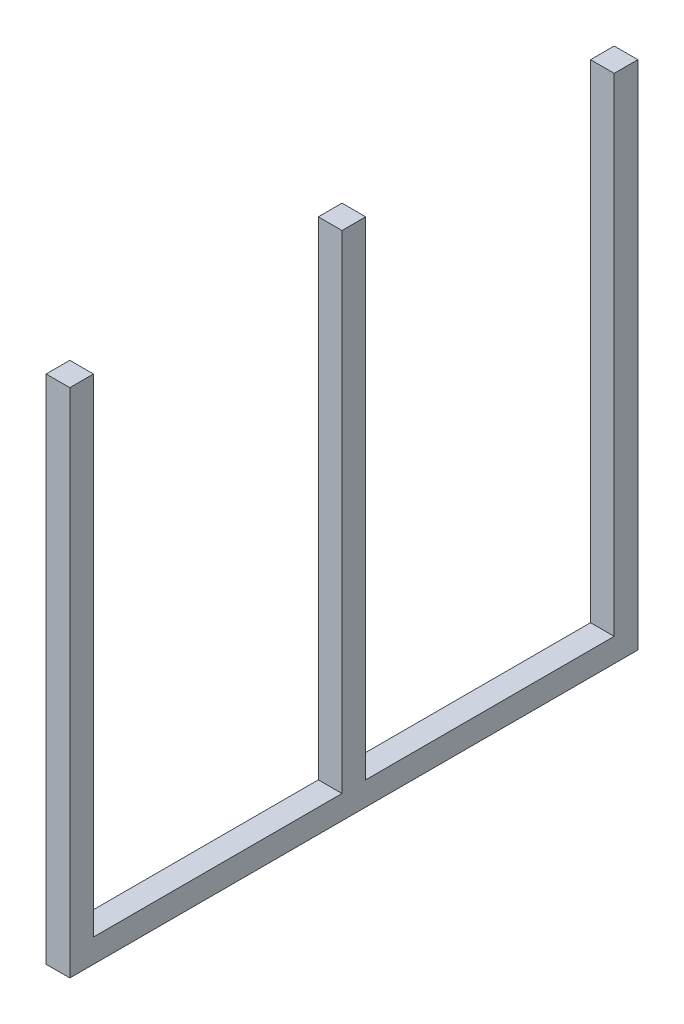
from build123d import *

# Parameters (mm, degrees)
SKETCH1_W           = 31.75
SKETCH1_H           = 31.75
SKETCH1_W_2         = 24.13
SKETCH1_H_2         = 24.13
BOSS_EXTRUDE1_DEPTH = 762
SKETCH14_W          = 31.75
SKETCH14_H          = 31.75
SKETCH14_W_2        = 25.4
SKETCH14_H_2        = 25.4
BOSS_EXTRUDE2_DEPTH = 685.8
SKETCH14_2_W        = 25.4
SKETCH14_2_H        = 25.4
BOSS_EXTRUDE3_DEPTH = 2.54
BOSS_EXTRUDE6_START = -683.26
SKETCH14_3_W        = 25.4
SKETCH14_3_H        = 25.4
BOSS_EXTRUDE6_DEPTH = 2.54
SKETCH1_2_W         = 24.13
SKETCH1_2_H         = 24.13
BOSS_EXTRUDE4_DEPTH = 2.54
BOSS_EXTRUDE5_START = 759.46
SKETCH1_3_W         = 24.13
SKETCH1_3_H         = 24.13
BOSS_EXTRUDE5_DEPTH = 2.54
LPATTERN4_COUNT     = 3
LPATTERN4_PITCH     = 365.125


with BuildPart() as part:
    # Sketch1 → Boss-Extrude1 (new body)
    with BuildSketch(Plane.XY):
        Rectangle(SKETCH1_W, SKETCH1_H)
        Rectangle(SKETCH1_W_2, SKETCH1_H_2, mode=Mode.SUBTRACT)
    extrude(amount=BOSS_EXTRUDE1_DEPTH)

    # Sketch14 → Boss-Extrude2 (add)
    with BuildSketch(Plane.XZ.offset(15.875)):
        with Locations((0, 746.125)):
            Rectangle(SKETCH14_W, SKETCH14_H)
        with Locations((0, 746.125)):
            Rectangle(SKETCH14_W_2, SKETCH14_H_2, mode=Mode.SUBTRACT)
    boss_extrude2 = extrude(amount=-BOSS_EXTRUDE2_DEPTH)

    # Sketch14_2 → Boss-Extrude3 (add)
    with BuildSketch(Plane.XZ.offset(15.875)):
        with Locations((0, 746.125)):
            Rectangle(SKETCH14_2_W, SKETCH14_2_H)
    boss_extrude3 = extrude(amount=-BOSS_EXTRUDE3_DEPTH)

    # Sketch14_3 → Boss-Extrude6 (add)
    with BuildSketch(Plane.XZ.offset(15.875).offset(BOSS_EXTRUDE6_START)):
        with Locations((0, 746.125)):
            Rectangle(SKETCH14_3_W, SKETCH14_3_H)
    boss_extrude6 = extrude(amount=-BOSS_EXTRUDE6_DEPTH)

    # Sketch1_2 → Boss-Extrude4 (add)
    with BuildSketch(Plane.XY):
        Rectangle(SKETCH1_2_W, SKETCH1_2_H)
    extrude(amount=BOSS_EXTRUDE4_DEPTH)

    # Sketch1_3 → Boss-Extrude5 (add)
    with BuildSketch(Plane.XY.offset(BOSS_EXTRUDE5_START)):
        Rectangle(SKETCH1_3_W, SKETCH1_3_H)
    extrude(amount=BOSS_EXTRUDE5_DEPTH)

    # LPattern4: Boss-Extrude2, Boss-Extrude3, Boss-Extrude6 ×3
    with Locations(*[(0, 0, -i * LPATTERN4_PITCH) for i in range(1, LPATTERN4_COUNT)]):
        add(boss_extrude2)
        add(boss_extrude3)
        add(boss_extrude6)


solid = part.part
